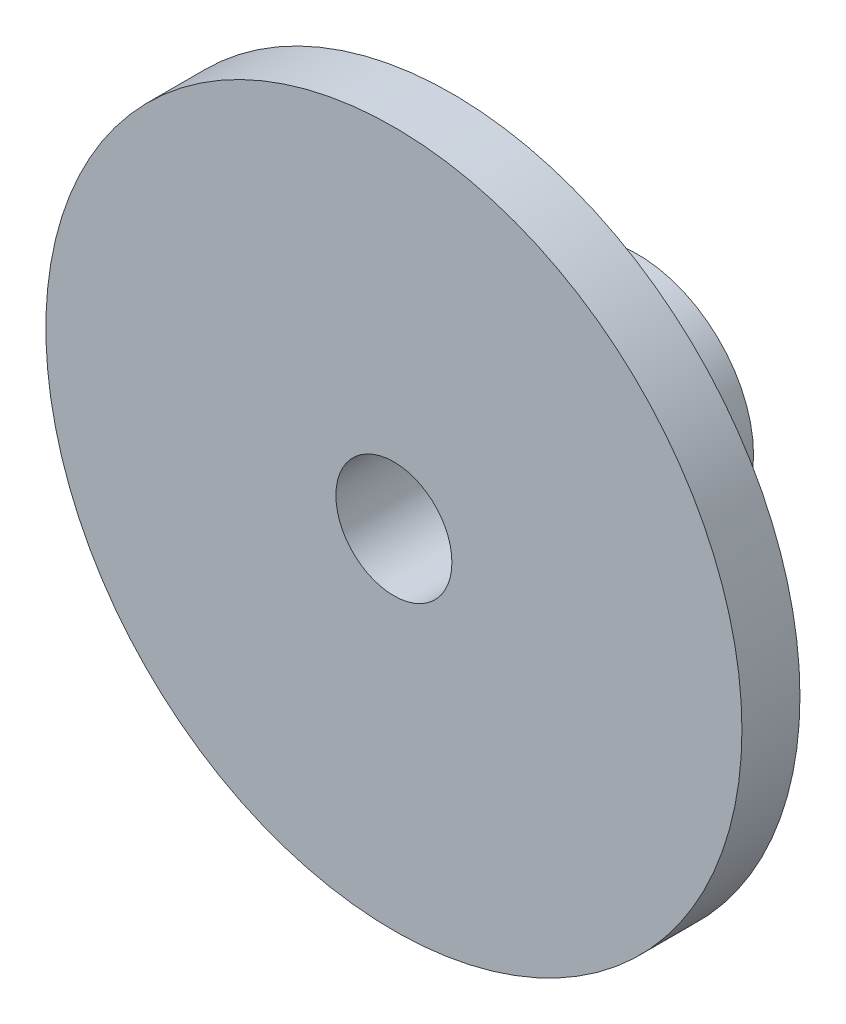
from build123d import *

# Parameters (mm, degrees)
SKETCH1_R           = 19.05
SKETCH1_R_2         = 3.175
BOSS_EXTRUDE1_DEPTH = 3.175
SKETCH2_R           = 6.35
SKETCH2_R_2         = 3.175
BOSS_EXTRUDE2_DEPTH = 10.16


with BuildPart() as part:
    # Sketch1 → Boss-Extrude1 (new body)
    with BuildSketch(Plane.XY):
        Circle(SKETCH1_R)
        Circle(SKETCH1_R_2, mode=Mode.SUBTRACT)
    extrude(amount=BOSS_EXTRUDE1_DEPTH)

    # Sketch2 → Boss-Extrude2 (add)
    with BuildSketch(Plane(origin=(0, 0, 0), x_dir=(-1, 0, 0), z_dir=(0, 0, -1))):
        Circle(SKETCH2_R)
        Circle(SKETCH2_R_2, mode=Mode.SUBTRACT)
    extrude(amount=BOSS_EXTRUDE2_DEPTH)


solid = part.part
